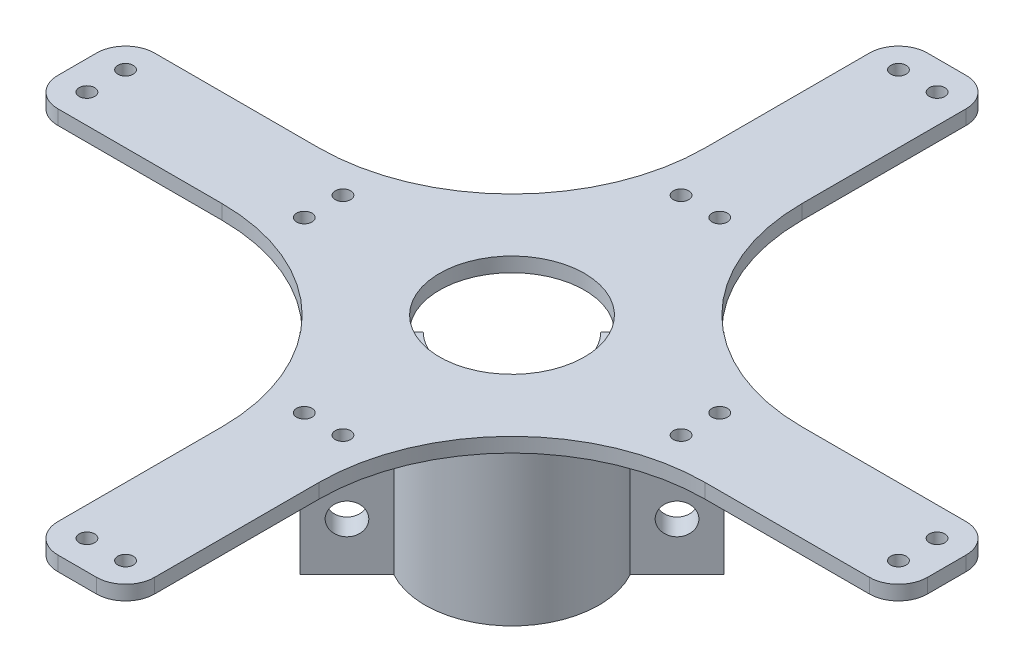
from build123d import *

# Parameters (mm, degrees)
BOSS_EXTRUDE1_DEPTH      = 1.5
M3_CLEARANCE_HOLE1_D     = 3.2
M3_CLEARANCE_HOLE1_DEPTH = 3
SKETCH5_R                = 15
CUT_EXTRUDE1_DEPTH       = 1
CUT_EXTRUDE1_DEPTH_BACK  = 4
SKETCH6_R                = 13
BOSS_EXTRUDE2_DEPTH      = 40
M6_CLEARANCE_HOLE1_D     = 6.4
M6_CLEARANCE_HOLE1_DEPTH = 10
CUT_EXTRUDE2_DEPTH       = 40


with BuildPart() as part:
    # Sketch1 → Boss-Extrude1 (new body, symmetric)
    with BuildSketch(Plane(origin=(0, 0, 0), x_dir=(1, 0, 0), z_dir=(0, 1, 0))):
        with BuildLine():
            Line((50, 10), (84, 10))
            ThreePointArc((84, 10), (88.242640687, 8.242640687), (90, 4))
            Line((90, 4), (90, -4))
            ThreePointArc((90, -4), (88.242640687, -8.242640687), (84, -10))
            Line((84, -10), (50, -10))
            ThreePointArc((50, -10), (21.715728753, -21.715728753), (10, -50))
            Line((10, -50), (10, -84))
            ThreePointArc((10, -84), (8.242640687, -88.242640687), (4, -90))
            Line((4, -90), (-4, -90))
            ThreePointArc((-4, -90), (-8.242640687, -88.242640687), (-10, -84))
            Line((-10, -84), (-10, -50))
            ThreePointArc((-10, -50), (-21.715728753, -21.715728753), (-50, -10))
            Line((-50, -10), (-84, -10))
            ThreePointArc((-84, -10), (-88.242640687, -8.242640687), (-90, -4))
            Line((-90, -4), (-90, 4))
            ThreePointArc((-90, 4), (-88.242640687, 8.242640687), (-84, 10))
            Line((-84, 10), (-50, 10))
            ThreePointArc((-50, 10), (-21.715728753, 21.715728753), (-10, 50))
            Line((-10, 50), (-10, 84))
            ThreePointArc((-10, 84), (-8.242640687, 88.242640687), (-4, 90))
            Line((-4, 90), (4, 90))
            ThreePointArc((4, 90), (8.242640687, 88.242640687), (10, 84))
            Line((10, 84), (10, 50))
            ThreePointArc((10, 50), (21.715728753, 21.715728753), (50, 10))
        make_face()
    extrude(amount=BOSS_EXTRUDE1_DEPTH, both=True)

    # M3 Clearance Hole1
    with Locations(Plane(origin=(0, 1.5, 0), x_dir=(1, 0, 0), z_dir=(0, 1, 0))):
        with Locations((-84, 4), (-84, -4), (-4, 84), (4, 84), (84, 4), (84, -4), (4, -84), (-4, -84), (-39, 4), (-39, -4), (39, 4), (39, -4), (4, -39), (-4, -39), (-4, 39), (4, 39)):
            Hole(M3_CLEARANCE_HOLE1_D / 2, depth=M3_CLEARANCE_HOLE1_DEPTH)

    # Sketch5 → Cut-Extrude1 (cut, two sides)
    with BuildSketch(Plane(origin=(0, 1.5, 0), x_dir=(1, 0, 0), z_dir=(0, 1, 0))) as cut_extrude1_sk:
        Circle(SKETCH5_R)
    extrude(amount=CUT_EXTRUDE1_DEPTH, mode=Mode.SUBTRACT)
    extrude(cut_extrude1_sk.sketch, amount=-CUT_EXTRUDE1_DEPTH_BACK, mode=Mode.SUBTRACT)

    # Sketch6 → Boss-Extrude2 (add)
    with BuildSketch(Plane.XZ.offset(1.5)):
        with BuildLine():
            Line((-15.762553167, 8.691485355), (-25.473103505, 18.402035693))
            Line((-25.473103505, 18.402035693), (-18.402035693, 25.473103505))
            Line((-18.402035693, 25.473103505), (-8.691485355, 15.762553167))
            ThreePointArc((-8.691485355, 15.762553167), (12.727922061, 12.727922061), (15.762553167, -8.691485355))
            Line((15.762553167, -8.691485355), (25.473103505, -18.402035693))
            Line((25.473103505, -18.402035693), (18.402035693, -25.473103505))
            Line((18.402035693, -25.473103505), (8.691485355, -15.762553167))
            ThreePointArc((8.691485355, -15.762553167), (-12.727922061, -12.727922061), (-15.762553167, 8.691485355))
        make_face()
        Circle(SKETCH6_R, mode=Mode.SUBTRACT)
    extrude(amount=BOSS_EXTRUDE2_DEPTH)

    # M6 Clearance Hole1
    with Locations(Plane(origin=(3.535533906, 0, 3.535533906), x_dir=(0.707106781, 0, -0.707106781), z_dir=(0.707106781, 0, 0.707106781))):
        with Locations((-24.158012459, -11.5), (-24.158012459, -31.5), (24.158012459, -11.5), (24.158012459, -31.5)):
            Hole(M6_CLEARANCE_HOLE1_D / 2, depth=M6_CLEARANCE_HOLE1_DEPTH)

    # Sketch11 → Cut-Extrude2 (cut)
    with BuildSketch(Plane.XZ.offset(41.5)):
        with BuildLine():
            Line((-21.937569599, 21.937569599), (21.937569599, -21.937569599))
            Line((21.937569599, -21.937569599), (18.402035693, -25.473103505))
            Line((18.402035693, -25.473103505), (8.691485355, -15.762553167))
            ThreePointArc((8.691485355, -15.762553167), (-12.727922061, -12.727922061), (-15.762553167, 8.691485355))
            Line((-15.762553167, 8.691485355), (-25.473103505, 18.402035693))
            Line((-25.473103505, 18.402035693), (-21.937569599, 21.937569599))
        make_face()
    extrude(amount=-CUT_EXTRUDE2_DEPTH, mode=Mode.SUBTRACT)


solid = part.part
